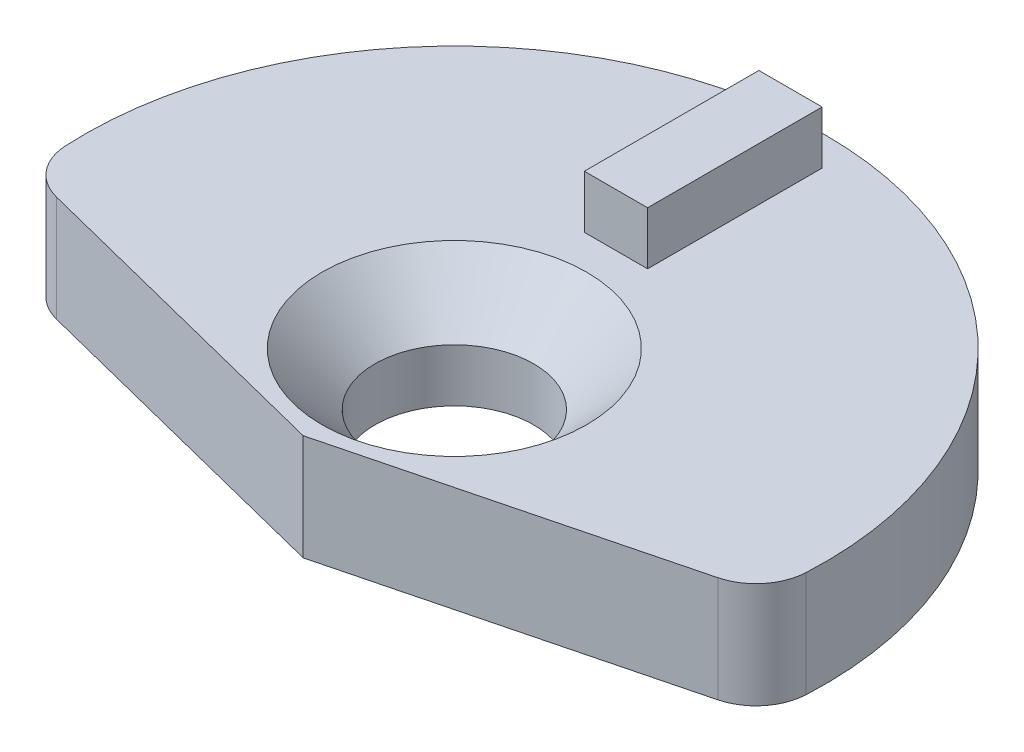
from build123d import *

# Parameters (mm, degrees)
SKETCH1_R           = 7
SKETCH1_R_2         = 1.5
BOSS_EXTRUDE1_DEPTH = 2
SKETCH2_W           = 15.705717302
SKETCH2_H           = 4.43210583
CUT_EXTRUDE1_DEPTH  = 2
CHAMFER1_SIZE       = 1
SKETCH3_W           = 1.195235373
SKETCH3_H           = 3.298389924
BOSS_EXTRUDE2_DEPTH = 1
CUT_EXTRUDE2_DEPTH  = 5
FILLET1_R           = 1


with BuildPart() as part:
    # Sketch1 → Boss-Extrude1 (new body)
    with BuildSketch(Plane(origin=(0, 0, 0), x_dir=(1, 0, 0), z_dir=(0, 1, 0))):
        with Locations((-0.805155446, -2.103263206)):
            Circle(SKETCH1_R)
        with Locations((-0.805155446, -2.103263206)):
            Circle(SKETCH1_R_2, mode=Mode.SUBTRACT)
    extrude(amount=BOSS_EXTRUDE1_DEPTH)

    # Sketch2 → Cut-Extrude1 (cut)
    with BuildSketch(Plane(origin=(0, 2, 0), x_dir=(1, 0, 0), z_dir=(0, 1, 0))):
        with Locations((-1.273649854, -7.174901084)):
            Rectangle(SKETCH2_W, SKETCH2_H)
    extrude(amount=-CUT_EXTRUDE1_DEPTH, mode=Mode.SUBTRACT)

    # Chamfer1
    chamfer1_edges = [part.edges().sort_by_distance(p)[0] for p in [
        (-2.305155446, 2, 2.103263206),
    ]]
    chamfer(chamfer1_edges, length=CHAMFER1_SIZE)

    # Sketch3 → Boss-Extrude2 (add)
    with BuildSketch(Plane(origin=(0, 2, 0), x_dir=(1, 0, 0), z_dir=(0, 1, 0))):
        with Locations((-0.879857657, 2.675462874)):
            Rectangle(SKETCH3_W, SKETCH3_H)
    extrude(amount=BOSS_EXTRUDE2_DEPTH)

    # Sketch4 → Cut-Extrude2 (cut)
    with BuildSketch(Plane(origin=(0, 2, 0), x_dir=(1, 0, 0), z_dir=(0, 1, 0))):
        Polygon((-0.805155446, -4.958848169), (-9.111708645, -2.862197678), (-9.111708645, -6.506834359), (7.404077395, -6.506834359), (7.404077395, -2.862197678), align=None)
    extrude(amount=-CUT_EXTRUDE2_DEPTH, mode=Mode.SUBTRACT)

    # Fillet1
    fillet1_edges = [part.edges().sort_by_distance(p)[0] for p in [
        (6.109528179, 1, 3.192827507),
        (-7.716407835, 1, 3.214384447),
    ]]
    fillet(fillet1_edges, radius=FILLET1_R)


solid = part.part
